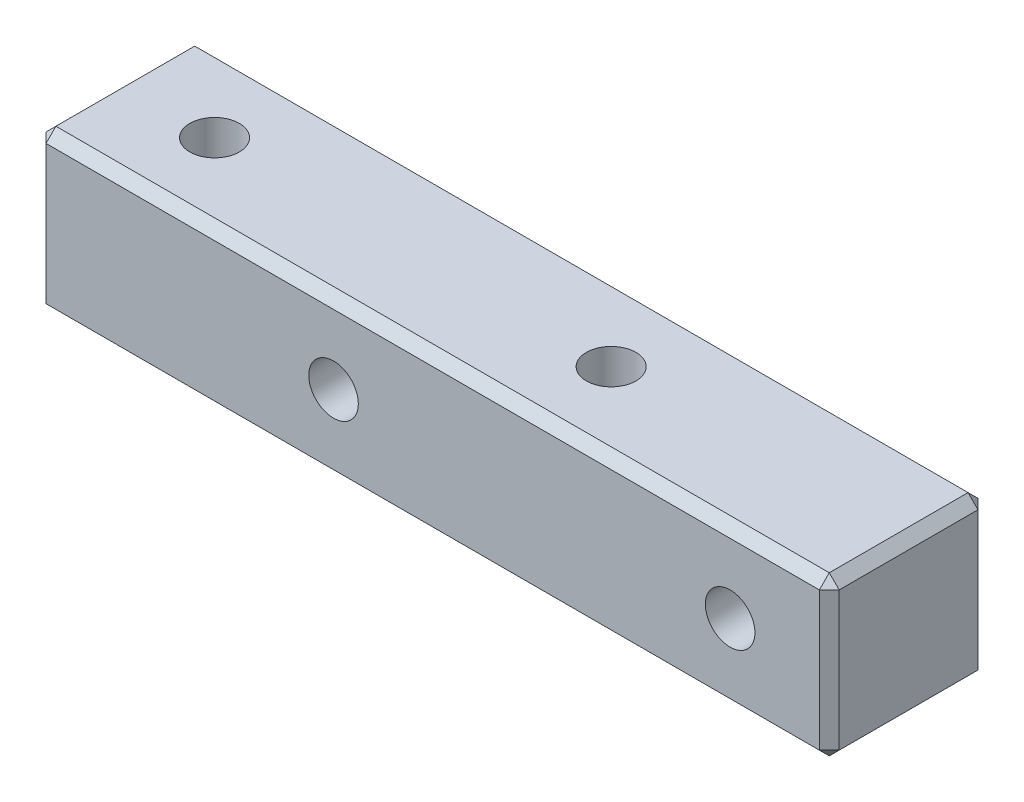
from build123d import *

# Parameters (mm, degrees)
SKETCH_2_W         = 40
SKETCH_2_H         = 8
SKETCH_2_R         = 0.5
EXTRUDE_1_DEPTH    = 4
HOLE_WIZARD_M3_1_D = 2.5
HOLE_WIZARD_M3_2_D = 2.5
CHAMFER_1_SIZE     = 0.5


with BuildPart() as part:
    # 草图2 → 凸台-拉伸1 (new body, symmetric)
    with BuildSketch(Plane.XY):
        with Locations((-15, 0)):
            Rectangle(SKETCH_2_W, SKETCH_2_H)
        with Locations((-20, 0)):
            Circle(SKETCH_2_R, mode=Mode.SUBTRACT)
        Circle(SKETCH_2_R, mode=Mode.SUBTRACT)
    extrude(amount=EXTRUDE_1_DEPTH, both=True)

    # M3 螺纹孔1 (through all)
    with Locations(Plane.XY.offset(4)):
        with Locations((0, 0), (-20, 0)):
            Hole(HOLE_WIZARD_M3_1_D / 2)

    # M3 螺纹孔2 (through all)
    with Locations(Plane(origin=(0, 4, 0), x_dir=(1, 0, 0), z_dir=(0, 1, 0))):
        with Locations((-10, 0), (-30, 0)):
            Hole(HOLE_WIZARD_M3_2_D / 2)

    # 倒角1
    chamfer_1_edges = [part.edges().sort_by_distance(p)[0] for p in [
        (-15, -4, 4),
        (5, 0, 4),
        (-15, 4, 4),
        (5, 0, -4),
        (-15, -4, -4),
        (-35, 0, -4),
        (-15, 4, -4),
        (-35, 0, 4),
        (5, 4, 0),
        (5, -4, 0),
        (-35, -4, 0),
        (-35, 4, 0),
    ]]
    chamfer(chamfer_1_edges, length=CHAMFER_1_SIZE)


solid = part.part
